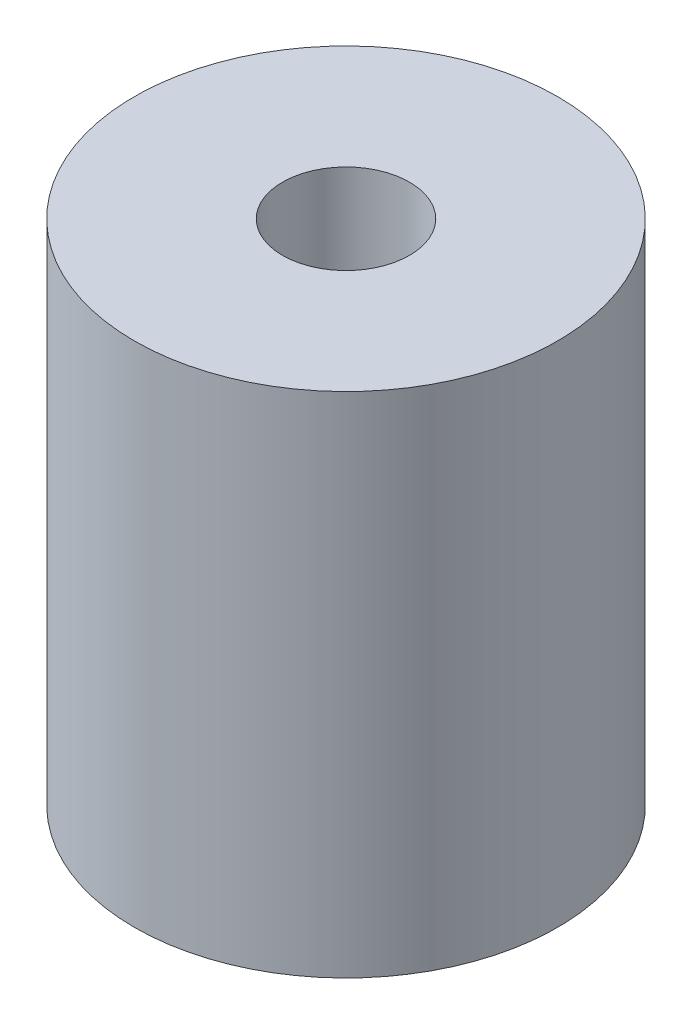
from build123d import *

# Parameters (mm, degrees)
SKETCH_1_R      = 5
SKETCH_1_R_2    = 1.5
EXTRUDE_1_DEPTH = 12


with BuildPart() as part:
    # 草图1 → 凸台-拉伸1 (new body)
    with BuildSketch(Plane(origin=(0, 0, 0), x_dir=(1, 0, 0), z_dir=(0, 1, 0))):
        Circle(SKETCH_1_R)
        Circle(SKETCH_1_R_2, mode=Mode.SUBTRACT)
    extrude(amount=EXTRUDE_1_DEPTH)


solid = part.part
